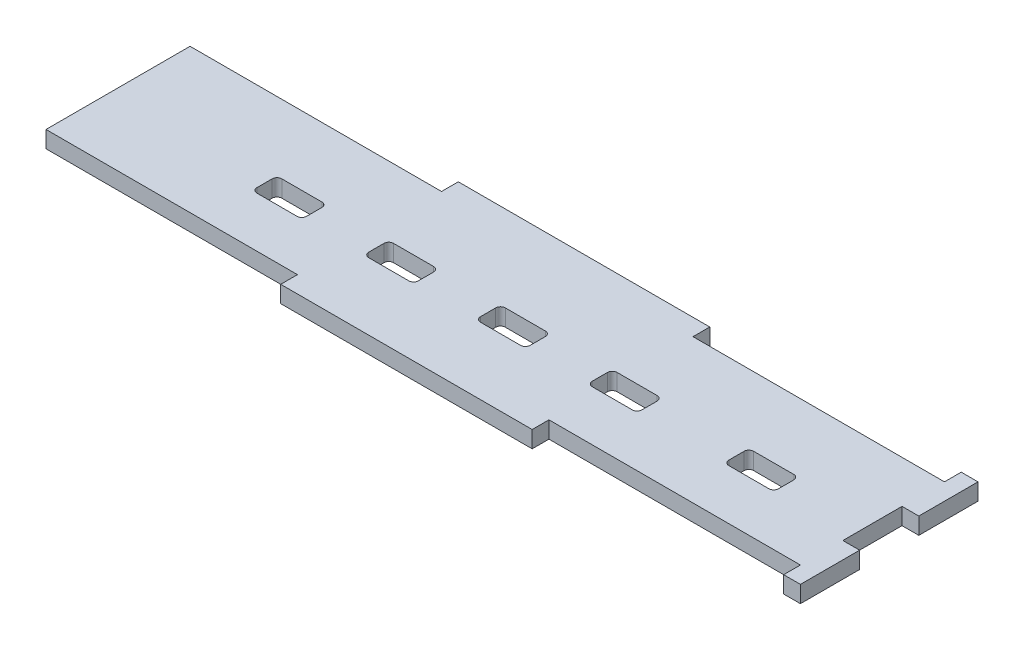
from build123d import *

# Parameters (mm, degrees)
BOSS_EXTRUDE1_DEPTH = 2.7


with BuildPart() as part:
    # Sketch1 → Boss-Extrude1 (new body)
    with BuildSketch(Plane(origin=(0, 0, 0), x_dir=(1, 0, 0), z_dir=(0, 1, 0))):
        Polygon((4, 2.833333333), (4, 12.366666667), (6.7, 12.366666667), (6.7, 21.9), (4, 21.9), (4, 19.2), (-36.5, 19.2), (-36.5, 21.9), (-77, 21.9), (-77, 19.2), (-117.5, 19.2), (-117.5, 12.366666667), (-117.5, 2.833333333), (-117.5, -4), (-77, -4), (-77, -6.7), (-36.5, -6.7), (-36.5, -4), (4, -4), (4, -6.7), (6.7, -6.7), (6.7, 2.833333333), align=None)
        with BuildLine():
            Line((-91.627899854, 8.1), (-85.172100146, 8.1))
            ThreePointArc((-85.172100146, 8.1), (-84.626142897, 7.873857103), (-84.4, 7.327899854))
            Line((-84.4, 7.327899854), (-84.4, 4.872100146))
            ThreePointArc((-84.4, 4.872100146), (-84.626142897, 4.326142897), (-85.172100146, 4.1))
            Line((-85.172100146, 4.1), (-91.627899854, 4.1))
            ThreePointArc((-91.627899854, 4.1), (-92.173857103, 4.326142897), (-92.4, 4.872100146))
            Line((-92.4, 4.872100146), (-92.4, 7.327899854))
            ThreePointArc((-92.4, 7.327899854), (-92.173857103, 7.873857103), (-91.627899854, 8.1))
        make_face(mode=Mode.SUBTRACT)
        with BuildLine():
            Line((-73.627899854, 8.1), (-67.172100146, 8.1))
            ThreePointArc((-67.172100146, 8.1), (-66.626142897, 7.873857103), (-66.4, 7.327899854))
            Line((-66.4, 7.327899854), (-66.4, 4.872100146))
            ThreePointArc((-66.4, 4.872100146), (-66.626142897, 4.326142897), (-67.172100146, 4.1))
            Line((-67.172100146, 4.1), (-73.627899854, 4.1))
            ThreePointArc((-73.627899854, 4.1), (-74.173857103, 4.326142897), (-74.4, 4.872100146))
            Line((-74.4, 4.872100146), (-74.4, 7.327899854))
            ThreePointArc((-74.4, 7.327899854), (-74.173857103, 7.873857103), (-73.627899854, 8.1))
        make_face(mode=Mode.SUBTRACT)
        with BuildLine():
            Line((-55.627899854, 8.1), (-49.172100146, 8.1))
            ThreePointArc((-49.172100146, 8.1), (-48.626142897, 7.873857103), (-48.4, 7.327899854))
            Line((-48.4, 7.327899854), (-48.4, 4.872100146))
            ThreePointArc((-48.4, 4.872100146), (-48.626142897, 4.326142897), (-49.172100146, 4.1))
            Line((-49.172100146, 4.1), (-55.627899854, 4.1))
            ThreePointArc((-55.627899854, 4.1), (-56.173857103, 4.326142897), (-56.4, 4.872100146))
            Line((-56.4, 4.872100146), (-56.4, 7.327899854))
            ThreePointArc((-56.4, 7.327899854), (-56.173857103, 7.873857103), (-55.627899854, 8.1))
        make_face(mode=Mode.SUBTRACT)
        with BuildLine():
            Line((-37.627899854, 8.1), (-31.172100146, 8.1))
            ThreePointArc((-31.172100146, 8.1), (-30.626142897, 7.873857103), (-30.4, 7.327899854))
            Line((-30.4, 7.327899854), (-30.4, 4.872100146))
            ThreePointArc((-30.4, 4.872100146), (-30.626142897, 4.326142897), (-31.172100146, 4.1))
            Line((-31.172100146, 4.1), (-37.627899854, 4.1))
            ThreePointArc((-37.627899854, 4.1), (-38.173857103, 4.326142897), (-38.4, 4.872100146))
            Line((-38.4, 4.872100146), (-38.4, 7.327899854))
            ThreePointArc((-38.4, 7.327899854), (-38.173857103, 7.873857103), (-37.627899854, 8.1))
        make_face(mode=Mode.SUBTRACT)
        with BuildLine():
            Line((-15.627899854, 8.1), (-9.172100146, 8.1))
            ThreePointArc((-9.172100146, 8.1), (-8.626142897, 7.873857103), (-8.4, 7.327899854))
            Line((-8.4, 7.327899854), (-8.4, 4.872100146))
            ThreePointArc((-8.4, 4.872100146), (-8.626142897, 4.326142897), (-9.172100146, 4.1))
            Line((-9.172100146, 4.1), (-15.627899854, 4.1))
            ThreePointArc((-15.627899854, 4.1), (-16.173857103, 4.326142897), (-16.4, 4.872100146))
            Line((-16.4, 4.872100146), (-16.4, 7.327899854))
            ThreePointArc((-16.4, 7.327899854), (-16.173857103, 7.873857103), (-15.627899854, 8.1))
        make_face(mode=Mode.SUBTRACT)
    extrude(amount=BOSS_EXTRUDE1_DEPTH)


solid = part.part
